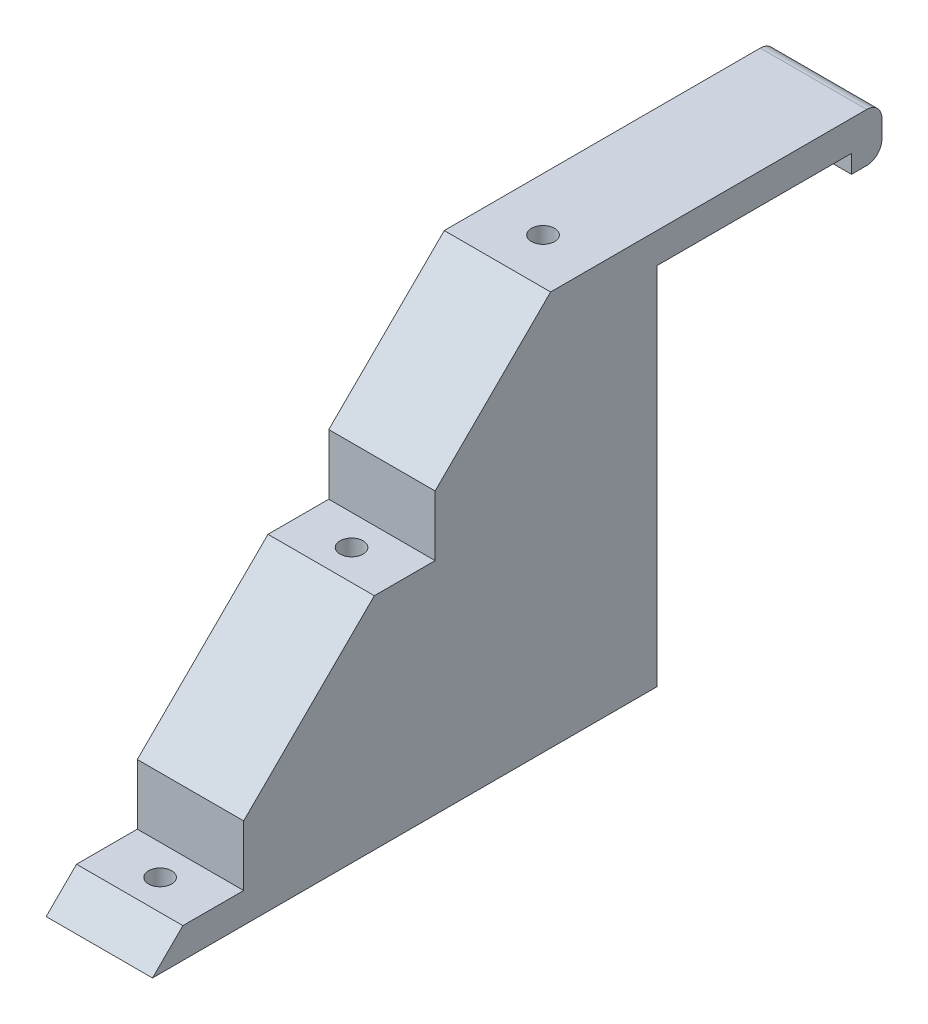
from build123d import *

# Parameters (mm, degrees)
BOSS_EXTRUDE1_DEPTH     = 11.1125
SKETCH3_W               = 22.225
SKETCH3_H               = 22.225
BOSS_EXTRUDE2_DEPTH     = 76.2
BOSS_EXTRUDE3_DEPTH     = 22.225
SKETCH6_R               = 2.413
CUT_EXTRUDE1_DEPTH      = 83.55
CUT_EXTRUDE2_DEPTH      = 1
CUT_EXTRUDE2_DEPTH_BACK = 23.225
FILLET1_R               = 3.175
SKETCH8_R               = 3.175
CUT_EXTRUDE3_DEPTH      = 9.525


with BuildPart() as part:
    # Sketch1 → Boss-Extrude1 (new body, symmetric)
    with BuildSketch(Plane(origin=(0, 0, 0), x_dir=(0, 0, -1), z_dir=(1, 0, 0))):
        Polygon((-22.225, 6.35), (0, 6.35), (46.99, 6.35), (46.99, -3.81), (40.64, -3.81), (40.64, 0), (0, 0), (-22.225, 0), align=None)
    extrude(amount=BOSS_EXTRUDE1_DEPTH, both=True)

    # Sketch3 → Boss-Extrude2 (add)
    with BuildSketch(Plane.XZ):
        with Locations((0, 11.1125)):
            Rectangle(SKETCH3_W, SKETCH3_H)
    extrude(amount=BOSS_EXTRUDE2_DEPTH)

    # Sketch5 → Boss-Extrude3 (add)
    with BuildSketch(Plane(origin=(11.1125, 0, 0), x_dir=(0, 0, -1), z_dir=(1, 0, 0))):
        Polygon((-22.225, 6.35), (-105.41, -76.2), (-22.225, -76.2), align=None)
    extrude(amount=-BOSS_EXTRUDE3_DEPTH)

    # Sketch6 → Cut-Extrude1 (cut, through all)
    with BuildSketch(Plane.XZ.offset(76.2)):
        with Locations((0, 92.71)):
            Circle(SKETCH6_R)
        with Locations((0, 12.7)):
            Circle(SKETCH6_R)
        with Locations((0, 52.705)):
            Circle(SKETCH6_R)
    extrude(amount=-CUT_EXTRUDE1_DEPTH, mode=Mode.SUBTRACT)

    # Sketch7 → Cut-Extrude2 (cut, two sides)
    with BuildSketch(Plane.ZY.offset(11.1125)) as cut_extrude2_sk:
        Polygon((46.355, -17.595801527), (46.355, -30.198854962), (59.055, -30.198854962), align=None)
        Polygon((86.36, -57.295419847), (86.36, -69.898473282), (99.06, -69.898473282), align=None)
    extrude(amount=CUT_EXTRUDE2_DEPTH, mode=Mode.SUBTRACT)
    extrude(cut_extrude2_sk.sketch, amount=-CUT_EXTRUDE2_DEPTH_BACK, mode=Mode.SUBTRACT)

    # Fillet1
    fillet1_edges = [part.edges().sort_by_distance(p)[0] for p in [
        (0, 6.35, -46.99),
        (0, -3.81, -46.99),
    ]]
    fillet(fillet1_edges, radius=FILLET1_R)

    # Sketch8 → Cut-Extrude3 (cut)
    with BuildSketch(Plane(origin=(0, 0, 0), x_dir=(-1, 0, 0), z_dir=(0, 0, -1))):
        with Locations((0, -52.3875)):
            Circle(SKETCH8_R)
    extrude(amount=-CUT_EXTRUDE3_DEPTH, mode=Mode.SUBTRACT)


solid = part.part
